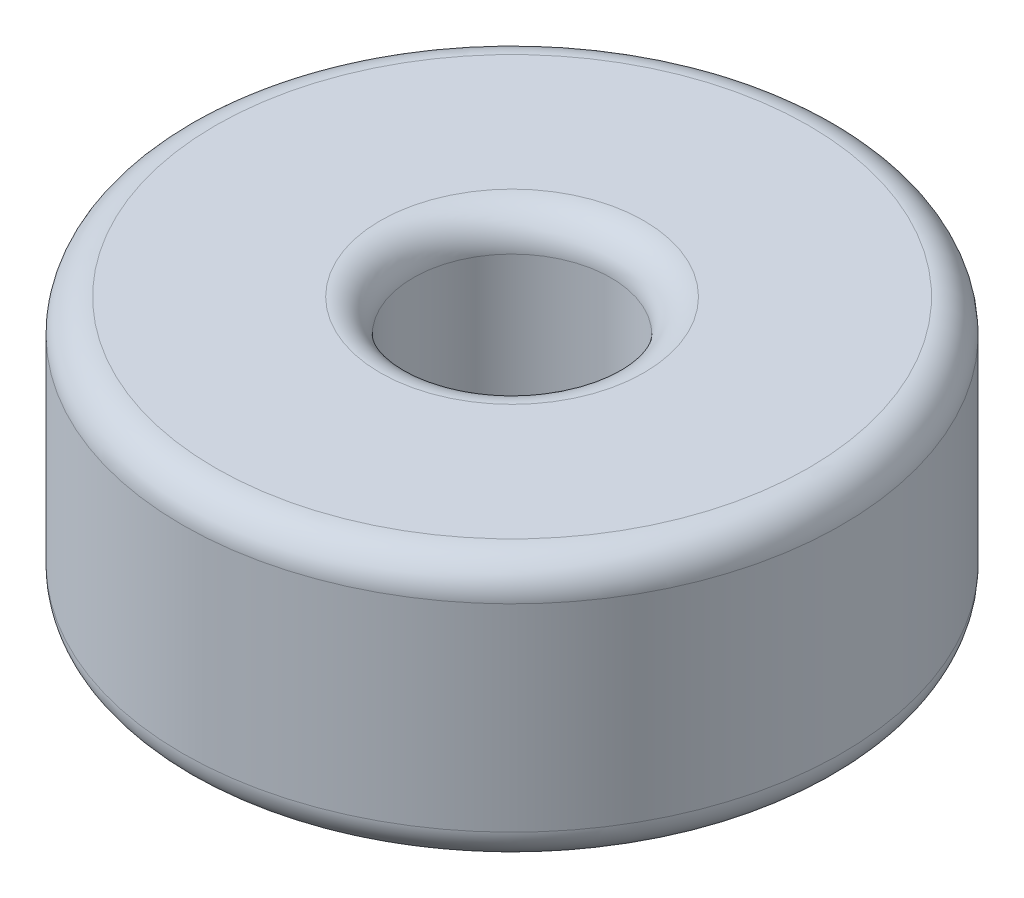
from build123d import *

# Parameters (mm, degrees)
SKETCH2_R           = 5
SKETCH2_R_2         = 1.5
BOSS_EXTRUDE1_DEPTH = 4
FILLET1_R           = 0.5
FILLET2_R           = 0.5


with BuildPart() as part:
    # Sketch2 → Boss-Extrude1 (new body)
    with BuildSketch(Plane(origin=(0, 0, 0), x_dir=(1, 0, 0), z_dir=(0, 1, 0))):
        Circle(SKETCH2_R)
        Circle(SKETCH2_R_2, mode=Mode.SUBTRACT)
    extrude(amount=BOSS_EXTRUDE1_DEPTH)

    # Fillet1
    fillet1_edges = [part.edges().sort_by_distance(p)[0] for p in [
        (-5, 0, 0),
        (-5, 4, 0),
    ]]
    fillet(fillet1_edges, radius=FILLET1_R)

    # Fillet2
    fillet2_edges = [part.edges().sort_by_distance(p)[0] for p in [
        (-1.5, 0, 0),
        (-1.5, 4, 0),
    ]]
    fillet(fillet2_edges, radius=FILLET2_R)


solid = part.part
